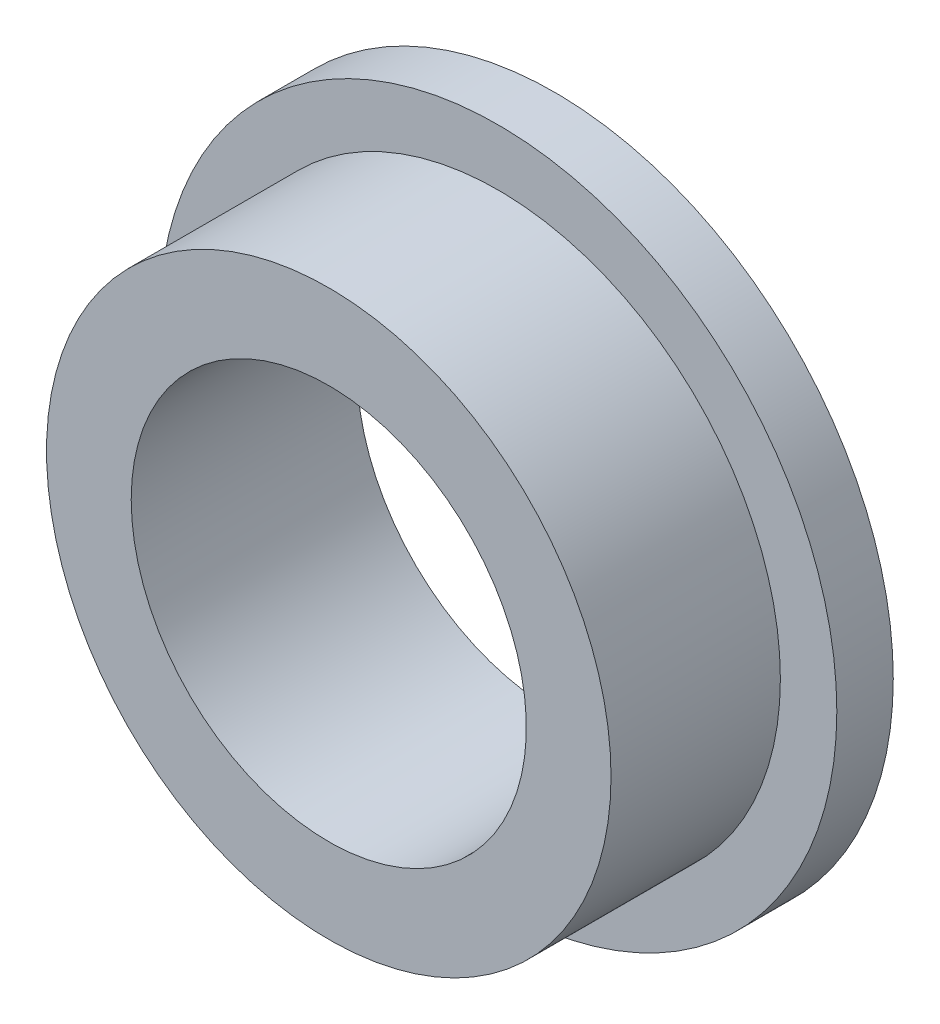
from build123d import *

# Parameters (mm, degrees)
SKETCH_2_R          = 6
EXTRUDE_1_DEPTH     = 1
SKETCH_3_R          = 5
EXTRUDE_2_DEPTH     = 3
SKETCH_4_R          = 3.5
CUT_EXTRUDE_1_DEPTH = 5


with BuildPart() as part:
    # Эскиз2 → Бобышка-Вытянуть1 (new body)
    with BuildSketch(Plane.XY):
        Circle(SKETCH_2_R)
    extrude(amount=EXTRUDE_1_DEPTH)

    # Эскиз3 → Бобышка-Вытянуть2 (add)
    with BuildSketch(Plane.XY.offset(1)):
        Circle(SKETCH_3_R)
    extrude(amount=EXTRUDE_2_DEPTH)

    # Эскиз4 → Вырез-Вытянуть1 (cut, through all)
    with BuildSketch(Plane(origin=(0, 0, 0), x_dir=(-1, 0, 0), z_dir=(0, 0, -1))):
        Circle(SKETCH_4_R)
    extrude(amount=-CUT_EXTRUDE_1_DEPTH, mode=Mode.SUBTRACT)


solid = part.part
